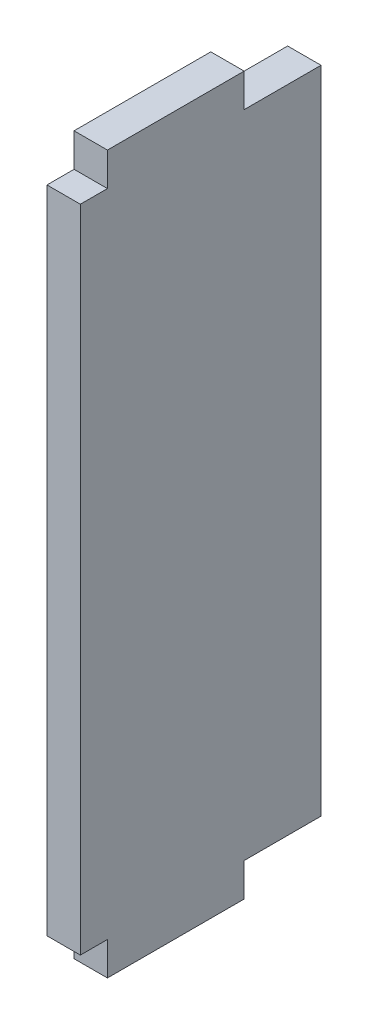
from build123d import *

# Parameters (mm, degrees)
SALIENTE_EXTRUIR1_DEPTH = 2.44


with BuildPart() as part:
    # Croquis1 → Saliente-Extruir1 (new body)
    with BuildSketch(Plane(origin=(0, 0, 0), x_dir=(0, 0, -1), z_dir=(1, 0, 0))):
        Polygon((3.18, -23.78), (8.8, -23.78), (8.8, 23.78), (3.18, 23.78), (3.18, 26.22), (-6.82, 26.22), (-6.82, 23.78), (-8.8, 23.78), (-8.8, -23.78), (-6.82, -23.78), (-6.82, -26.22), (3.18, -26.22), align=None)
    extrude(amount=SALIENTE_EXTRUIR1_DEPTH)


solid = part.part
